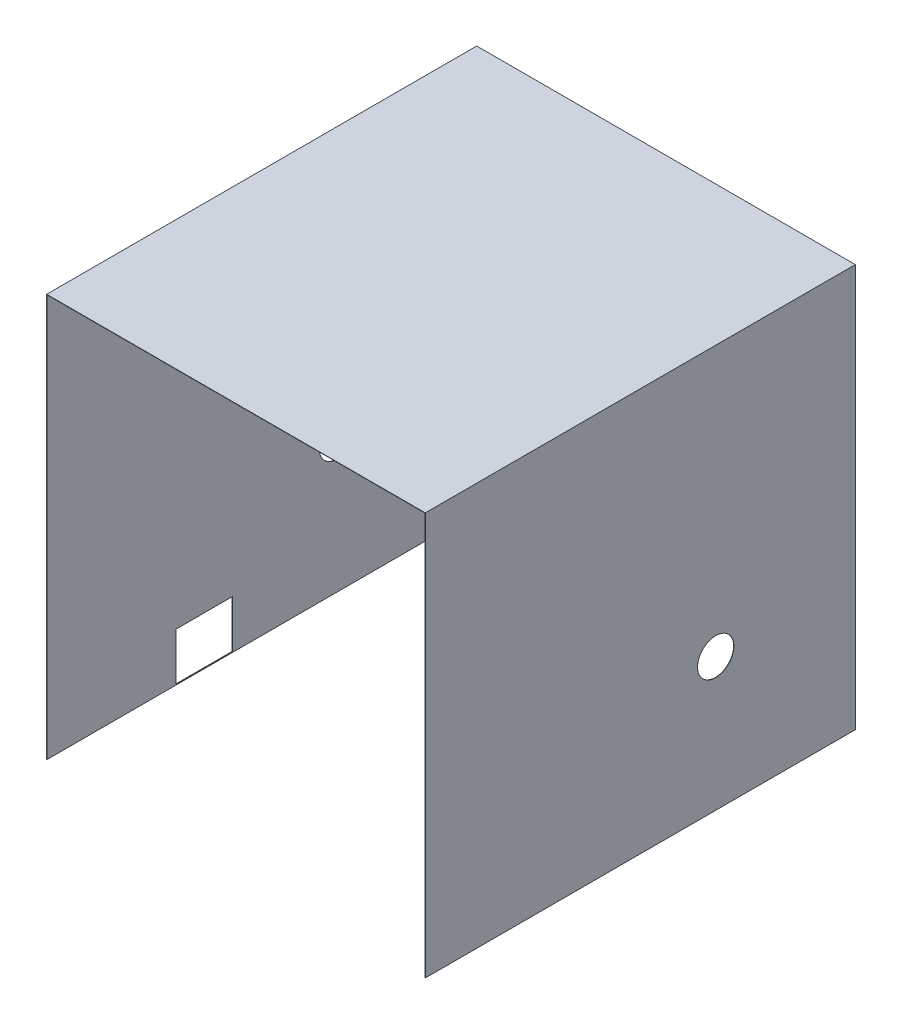
from build123d import *

# Parameters (mm, degrees)
BOSS_EXTRUDE1_DEPTH = 533
SKETCH2_R           = 22.5
CUT_EXTRUDE1_DEPTH  = 533
SKETCH3_W           = 70
SKETCH3_H           = 59
CUT_EXTRUDE2_DEPTH  = 243


with BuildPart() as part:
    # Sketch1 → Boss-Extrude1 (new body)
    with BuildSketch(Plane.XY):
        Polygon((-344.517995001, 0), (-344.517995001, 499.3), (124.782004999, 499.3), (124.782004999, 0), (124.432004999, 0), (124.432004999, 498.95), (-344.167995001, 498.95), (-344.167995001, 0), align=None)
    extrude(amount=BOSS_EXTRUDE1_DEPTH)

    # Sketch2 → Cut-Extrude1 (cut)
    with BuildSketch(Plane(origin=(124.782004999, 0, 0), x_dir=(0, 0, -1), z_dir=(1, 0, 0))):
        with Locations((-173, 165)):
            Circle(SKETCH2_R)
    extrude(amount=-CUT_EXTRUDE1_DEPTH, mode=Mode.SUBTRACT)

    # Sketch3 → Cut-Extrude2 (cut)
    with BuildSketch(Plane.ZY.offset(344.517995001)):
        with Locations((338, 30.5)):
            Rectangle(SKETCH3_W, SKETCH3_H)
    extrude(amount=-CUT_EXTRUDE2_DEPTH, mode=Mode.SUBTRACT)


solid = part.part
